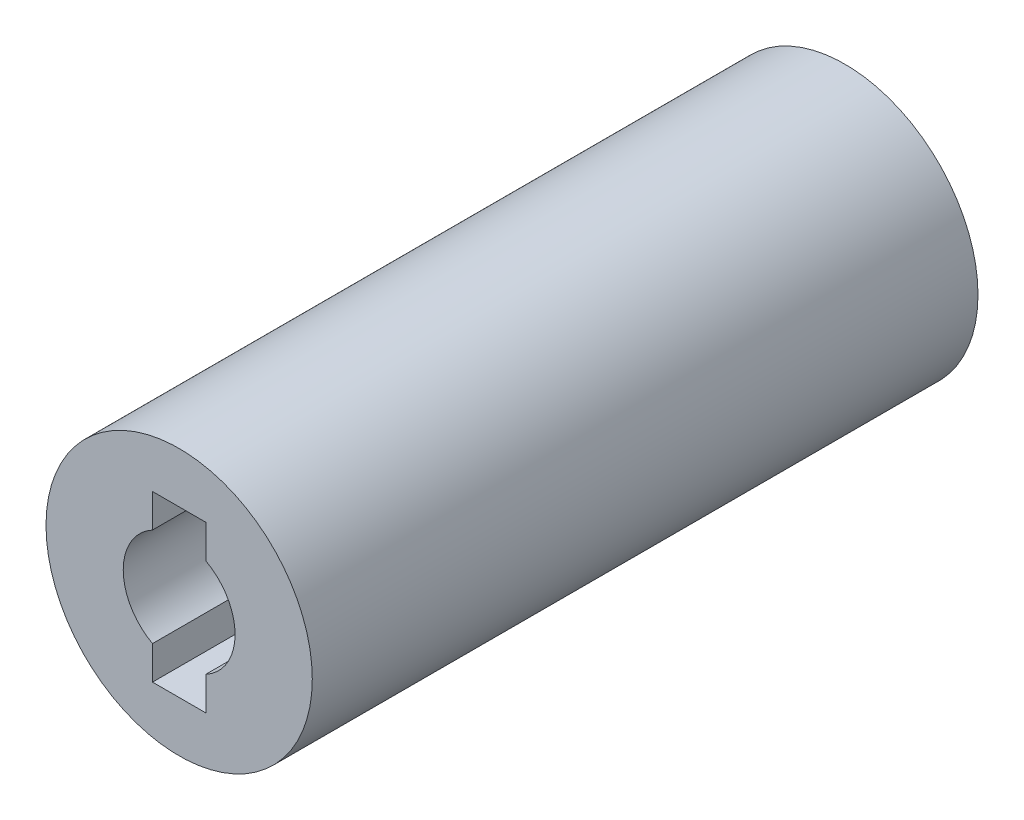
from build123d import *

# Parameters (mm, degrees)
SKETCH1_R           = 5
BOSS_EXTRUDE1_DEPTH = 25
SKETCH2_R           = 2.1
CUT_EXTRUDE1_DEPTH  = 10
SKETCH3_W           = 2
SKETCH3_H           = 6.2
CUT_EXTRUDE2_DEPTH  = 10


with BuildPart() as part:
    # Sketch1 → Boss-Extrude1 (new body)
    with BuildSketch(Plane.XY):
        Circle(SKETCH1_R)
    extrude(amount=BOSS_EXTRUDE1_DEPTH)

    # Sketch2 → Cut-Extrude1 (cut)
    with BuildSketch(Plane.XY.offset(25)):
        Circle(SKETCH2_R)
    extrude(amount=-CUT_EXTRUDE1_DEPTH, mode=Mode.SUBTRACT)

    # Sketch3 → Cut-Extrude2 (cut)
    with BuildSketch(Plane.XY.offset(25)):
        Rectangle(SKETCH3_W, SKETCH3_H)
    extrude(amount=-CUT_EXTRUDE2_DEPTH, mode=Mode.SUBTRACT)


solid = part.part
